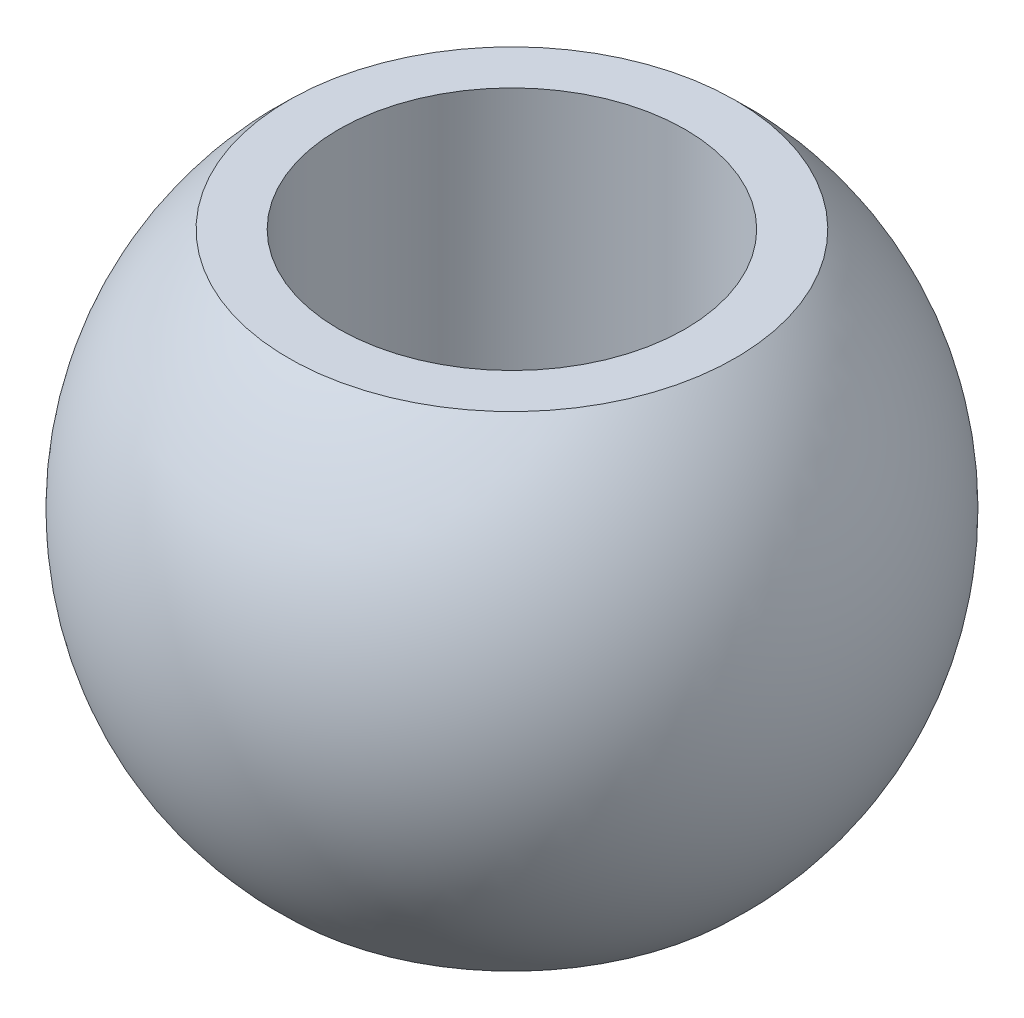
from build123d import *


with BuildPart() as part:
    # Szkic1 → Obrót1 (revolve)
    with BuildSketch(Plane.XY):
        with BuildLine():
            Line((5, -7), (5, 7))
            Line((5, 7), (6.452162428, 7))
            ThreePointArc((6.452162428, 7), (9.52, 0), (6.452162428, -7))
            Line((6.452162428, -7), (5, -7))
        make_face()
    revolve(axis=Axis((0, -11.1, 0), (0, 1, 0)))


solid = part.part
